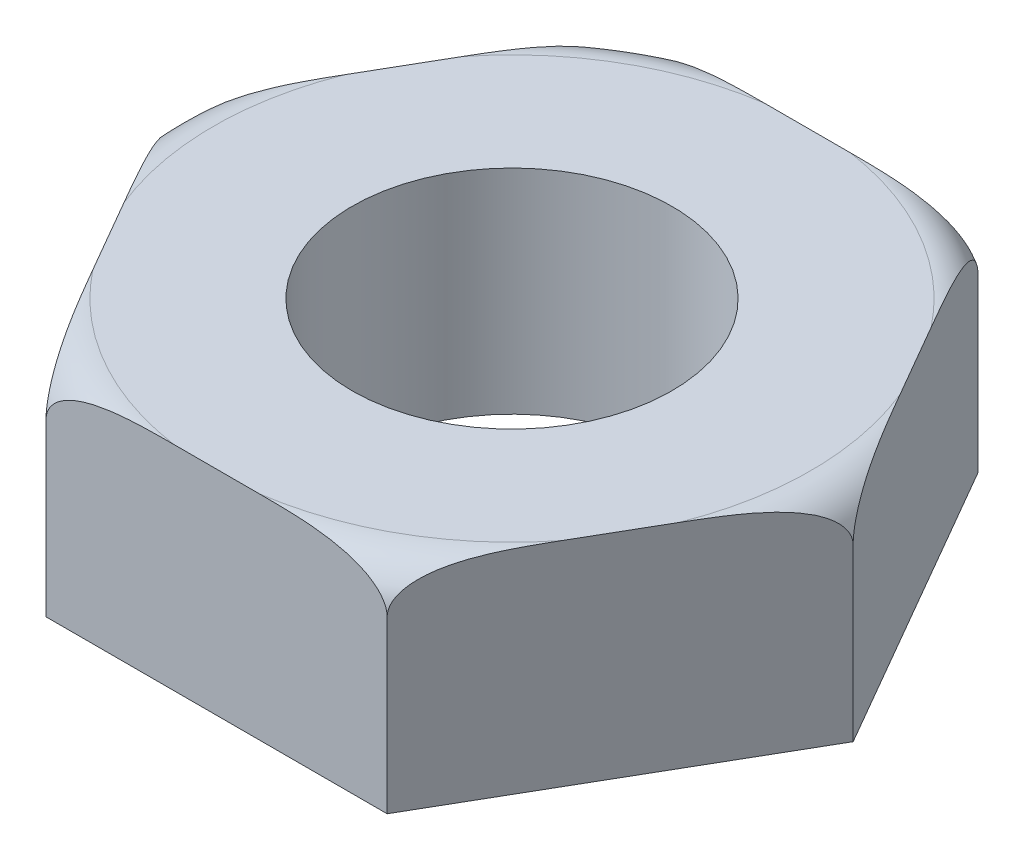
from build123d import *

# Parameters (mm, degrees)
BOSS_EXTRUDE1_DEPTH = 25
SKETCH3_R           = 18.75
CUT_EXTRUDE1_DEPTH  = 49


with BuildPart() as part:
    # Sketch1 → Boss-Extrude1 (new body)
    with BuildSketch(Plane(origin=(0, 0, 0), x_dir=(1, 0, 0), z_dir=(0, 1, 0))):
        Polygon((40, 0), (20, 34.641016151), (-20, 34.641016151), (-40, 0), (-20, -34.641016151), (20, -34.641016151), align=None)
    extrude(amount=BOSS_EXTRUDE1_DEPTH)

    # Sketch2 → Cut-Revolve1 (revolve, cut)
    with BuildSketch(Plane.XY):
        with BuildLine():
            Line((-40, 19.787670443), (-40, 20))
            ThreePointArc((-40, 20), (-38.535533906, 23.535533906), (-35, 25))
            Line((-35, 25), (-37.757743641, 31.268029575))
            Line((-37.757743641, 31.268029575), (-44.972742857, 23.763902868))
            Line((-44.972742857, 23.763902868), (-40, 19.787670443))
        make_face()
    revolve(axis=Axis((0, 25, 0), (0, 1, 0)), mode=Mode.SUBTRACT)

    # Sketch3 → Cut-Extrude1 (cut)
    with BuildSketch(Plane(origin=(0, 25, 0), x_dir=(1, 0, 0), z_dir=(0, 1, 0))):
        Circle(SKETCH3_R)
    extrude(amount=-CUT_EXTRUDE1_DEPTH, mode=Mode.SUBTRACT)


solid = part.part
